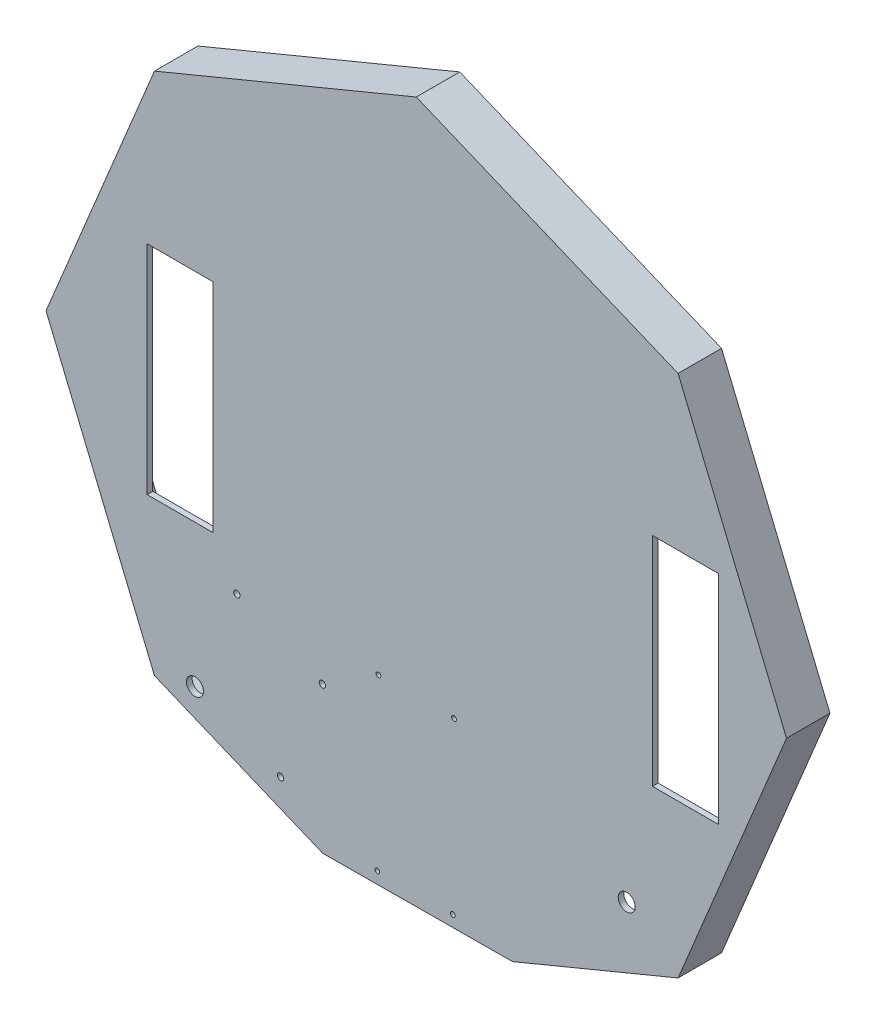
from build123d import *

# Parameters (mm, degrees)
BOSS_EXTRUDE1_DEPTH     = 3
SKETCH5_W               = 150
SKETCH5_H               = 20
BOSS_EXTRUDE2_DEPTH     = 3
MIRROR2_COPY_1_SKETCH_W = 150
MIRROR2_COPY_1_SKETCH_H = 20
MIRROR2_COPY_1_DEPTH    = 3
SKETCH6_W               = 23
SKETCH6_H               = 150
BOSS_EXTRUDE3_DEPTH     = 3
MIRROR4_COPY_1_SKETCH_W = 23
MIRROR4_COPY_1_SKETCH_H = 150
MIRROR4_COPY_1_DEPTH    = 3
MIRROR4_COPY_2_SKETCH_W = 23
MIRROR4_COPY_2_SKETCH_H = 150
MIRROR4_COPY_2_DEPTH    = 3
FILLET1_R               = 2
SKETCH4_W               = 35
SKETCH4_H               = 115
CUT_EXTRUDE1_DEPTH      = 10
TAP_DRILL_FOR_M3_TAP2_D = 2.5
TAP_DRILL_FOR_M3_TAP3_D = 2.5
M3_CLEARANCE_HOLE1_D    = 3.4
M8_CLEARANCE_HOLE1_D    = 9
CUT_EXTRUDE2_DEPTH      = 20
CUT_EXTRUDE2_DEPTH_BACK = 3


with BuildPart() as part:
    # Sketch1 → Boss-Extrude1 (new body)
    with BuildSketch(Plane.XY):
        Polygon((0, 195.984444731), (-138.581929877, 138.581929877), (-195.984444731, 0), (-138.581929877, -138.581929877), (0, -195.984444731), (138.581929877, -138.581929877), (195.984444731, 0), (138.581929877, 138.581929877), align=None)
    boss_extrude1 = extrude(amount=BOSS_EXTRUDE1_DEPTH)

    # Sketch5 → Boss-Extrude2 (add)
    with BuildSketch(Plane(origin=(-69.290964938, -167.283187304, 0), x_dir=(0.923879533, -0.382683432, 0), z_dir=(-0.382683432, -0.923879533, 0))):
        with Locations((0, -10)):
            Rectangle(SKETCH5_W, SKETCH5_H)
    boss_extrude2 = extrude(amount=-BOSS_EXTRUDE2_DEPTH)

    # Mirror1: Boss-Extrude2 across plane
    add(boss_extrude2.mirror(Plane.ZX))

    # Mirror2: Boss-Extrude2 across plane
    add(boss_extrude2.mirror(Plane(origin=(0, 0, 0), x_dir=(0, 0, 1), z_dir=(1, 0, 0))))

    # Mirror2 copy 1 sketch → Mirror2 copy 1 (add)
    with BuildSketch(Plane(origin=(69.290964938, 167.283187304, 0), x_dir=(-0.923879533, 0.382683432, 0), z_dir=(0.382683432, 0.923879533, 0))):
        with Locations((0, -10)):
            Rectangle(MIRROR2_COPY_1_SKETCH_W, MIRROR2_COPY_1_SKETCH_H)
    extrude(amount=-MIRROR2_COPY_1_DEPTH)

    # Sketch6 → Boss-Extrude3 (add)
    with BuildSketch(Plane(origin=(-167.283187304, -69.290964938, 0), x_dir=(0, 0, 1), z_dir=(-0.923879533, -0.382683432, 0))):
        with Locations((-8.5, 0)):
            Rectangle(SKETCH6_W, SKETCH6_H)
    boss_extrude3 = extrude(amount=-BOSS_EXTRUDE3_DEPTH)

    # Mirror3: Boss-Extrude3 across plane
    add(boss_extrude3.mirror(Plane.ZX))

    # Mirror4: Boss-Extrude1 across plane
    add(boss_extrude1.mirror(Plane(origin=(0, 0, 0), x_dir=(0, 0, 1), z_dir=(1, 0, 0))))

    # Mirror4 copy 1 sketch → Mirror4 copy 1 (add)
    with BuildSketch(Plane(origin=(167.283187304, 69.290964938, 0), x_dir=(0, 0, 1), z_dir=(0.923879533, 0.382683432, 0))):
        with Locations((-8.5, 0)):
            Rectangle(MIRROR4_COPY_1_SKETCH_W, MIRROR4_COPY_1_SKETCH_H)
    extrude(amount=-MIRROR4_COPY_1_DEPTH)

    # Mirror4 copy 2 sketch → Mirror4 copy 2 (add)
    with BuildSketch(Plane(origin=(167.283187304, -69.290964938, 0), x_dir=(0, 0, 1), z_dir=(0.923879533, -0.382683432, 0))):
        with Locations((-8.5, 0)):
            Rectangle(MIRROR4_COPY_2_SKETCH_W, MIRROR4_COPY_2_SKETCH_H)
    extrude(amount=-MIRROR4_COPY_2_DEPTH)

    # Fillet1
    fillet1_edges = [part.edges().sort_by_distance(p)[0] for p in [
        (-164.511548707, -68.142914641, 0),
        (-164.511548707, 68.142914641, 0),
        (164.511548707, 68.142914641, 0),
        (164.511548707, -68.142914641, 0),
        (-68.142914641, 164.511548707, 0),
        (68.142914641, 164.511548707, 0),
        (-68.142914641, -164.511548707, 0),
        (68.142914641, -164.511548707, 0),
    ]]
    fillet(fillet1_edges, radius=FILLET1_R)

    # Sketch4 → Cut-Extrude1 (cut)
    with BuildSketch(Plane(origin=(0, 0, 0), x_dir=(-1, 0, 0), z_dir=(0, 0, -1))):
        with Locations((-142.5, 0)):
            Rectangle(SKETCH4_W, SKETCH4_H)
        with Locations((125, 0)):
            Rectangle(SKETCH4_W, SKETCH4_H)
    extrude(amount=-CUT_EXTRUDE1_DEPTH, mode=Mode.SUBTRACT)

    # Tap Drill for M3 Tap2 (through all)
    with Locations(Plane(origin=(0, 0, 0), x_dir=(-1, 0, 0), z_dir=(0, 0, -1))):
        with Locations((-19.343368816, -169.062877249), (20.628515923, -169.078590597)):
            Hole(TAP_DRILL_FOR_M3_TAP2_D / 2)

    # Tap Drill for M3 Tap3 (through all)
    with Locations(Plane(origin=(0, 0, 0), x_dir=(-1, 0, 0), z_dir=(0, 0, -1))):
        with Locations((-20, -78.890298866), (20, -78.890298866)):
            Hole(TAP_DRILL_FOR_M3_TAP3_D / 2)

    # M3 Clearance Hole1 (through all)
    with Locations(Plane.XY.offset(3)):
        with Locations((-49.680592478, -98.01502722), (-71.876231555, -151.600040105), (-117.146328648, -132.848551919), (-94.950689571, -79.263539034)):
            Hole(M3_CLEARANCE_HOLE1_D / 2)

    # M8 Clearance Hole1 (through all)
    with Locations(Plane.XY.offset(3)):
        with Locations((111.402419859, -117.376896871), (-117.146328648, -132.848551919)):
            Hole(M8_CLEARANCE_HOLE1_D / 2)

    # Sketch21 → Cut-Extrude2 (cut, two sides)
    with BuildSketch(Plane(origin=(0, 0, 0), x_dir=(-1, 0, 0), z_dir=(0, 0, -1))) as cut_extrude2_sk:
        Polygon((0, -195.984444731), (-50.931031111, -174.8881209), (49.535442442, -175.466192654), align=None)
    extrude(amount=CUT_EXTRUDE2_DEPTH, mode=Mode.SUBTRACT)
    extrude(cut_extrude2_sk.sketch, amount=-CUT_EXTRUDE2_DEPTH_BACK, mode=Mode.SUBTRACT)


solid = part.part
